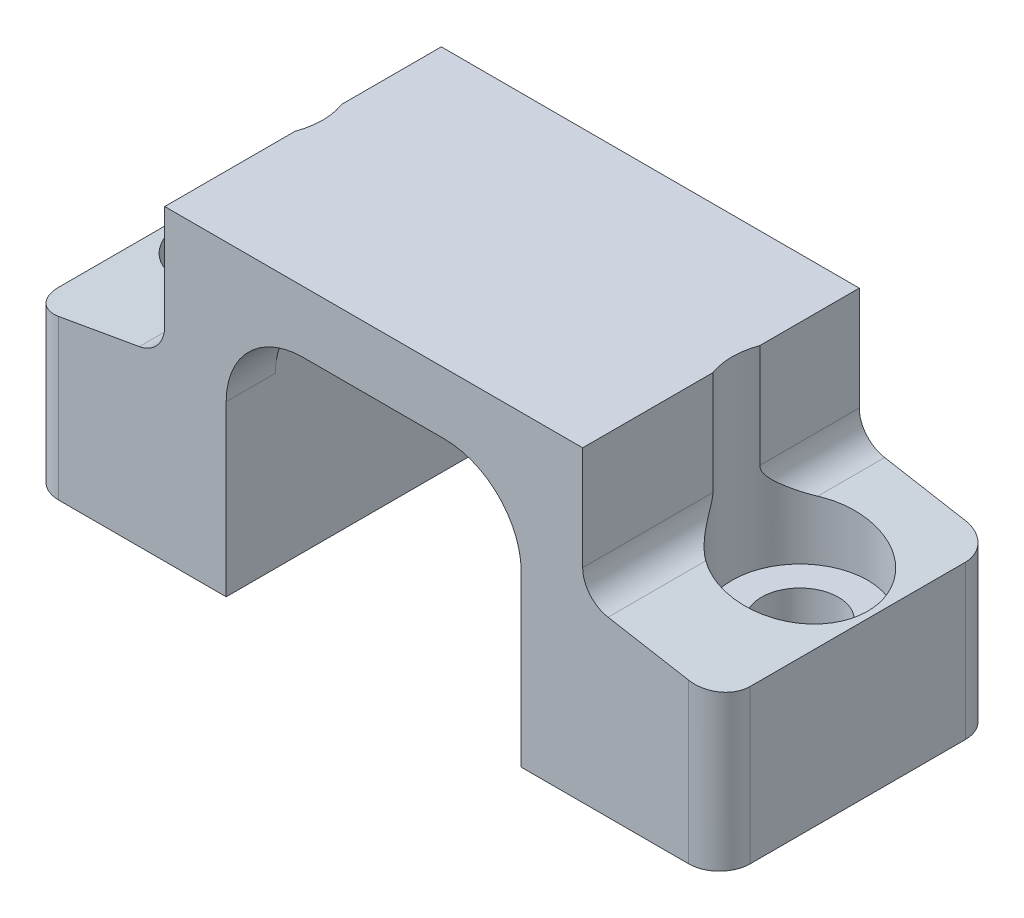
from build123d import *

# Parameters (mm, degrees)
BOSS_EXTRUDE1_DEPTH = 22.86
BOSS_EXTRUDE2_DEPTH = 13.462
BOSS_EXTRUDE3_START = -1.27
BOSS_EXTRUDE3_DEPTH = 1.905
BOSS_EXTRUDE4_START = -1.27
BOSS_EXTRUDE4_DEPTH = 3.81
SKETCH8_R           = 2.8
SKETCH8_R_2         = 1.5875
CUT_EXTRUDE1_DEPTH  = 8
SKETCH9_W           = 28.575
SKETCH9_H           = 11.43
CUT_EXTRUDE2_DEPTH  = 13.7
FILLET1_R           = 1.27


with BuildPart() as part:
    # Sketch1 → Boss-Extrude1 (new body)
    with BuildSketch(Plane.XY):
        Polygon((-6.096, 10.16), (6.096, 10.16), (6.096, 0), (14.2875, 0), (14.2875, 6.35), (8.636, 7.346511931), (8.636, 12.7), (-8.636, 12.7), (-8.636, 7.346511931), (-14.2875, 6.35), (-14.2875, 0), (-6.096, 0), align=None)
    extrude(amount=-BOSS_EXTRUDE1_DEPTH)

    # Sketch2 → Boss-Extrude2 (add)
    with BuildSketch(Plane.XY):
        with BuildLine():
            Line((2.921, 10.16), (6.096, 10.16))
            Line((6.096, 10.16), (6.096, 6.985))
            ThreePointArc((6.096, 6.985), (5.16606403, 9.23006403), (2.921, 10.16))
        make_face()
        with BuildLine():
            Line((-6.096, 10.16), (-6.096, 6.985))
            ThreePointArc((-6.096, 6.985), (-5.16606403, 9.23006403), (-2.921, 10.16))
            Line((-2.921, 10.16), (-6.096, 10.16))
        make_face()
    extrude(amount=-BOSS_EXTRUDE2_DEPTH)

    # Sketch3 → Boss-Extrude3 (add)
    with BuildSketch(Plane.XY.offset(-13.462).offset(BOSS_EXTRUDE3_START)):
        with BuildLine():
            Line((-6.096, 10.16), (-6.096, 6.985))
            ThreePointArc((-6.096, 6.985), (-5.16606403, 9.23006403), (-2.921, 10.16))
            Line((-2.921, 10.16), (-6.096, 10.16))
        make_face()
    extrude(amount=-BOSS_EXTRUDE3_DEPTH)

    # Sketch4 → Boss-Extrude4 (add)
    with BuildSketch(Plane.XY.offset(-16.637).offset(BOSS_EXTRUDE4_START)):
        with BuildLine():
            Line((-6.096, 10.16), (-6.096, 6.985))
            ThreePointArc((-6.096, 6.985), (-5.16606403, 9.23006403), (-2.921, 10.16))
            Line((-2.921, 10.16), (-6.096, 10.16))
        make_face()
    extrude(amount=-BOSS_EXTRUDE4_DEPTH)

    # Sketch6 → Cut-Revolve1 (revolve, cut)
    with BuildSketch(Plane.XY.offset(-5.08)):
        Polygon((11.262482277, -1.27), (12.849982277, -1.27), (12.849982277, 6.60347316), (12.849982277, 9.423392242), (11.262482277, 9.423392242), (11.262482277, 6.883392242), align=None)
    cut_revolve1 = revolve(axis=Axis((11.262482277, -1.27, -5.08), (0, -1, 0)), mode=Mode.SUBTRACT)

    # Mirror1: Cut-Revolve1 across plane
    add(cut_revolve1.mirror(Plane(origin=(0, 0, 0), x_dir=(0, 0, 1), z_dir=(1, 0, 0))), mode=Mode.SUBTRACT)

    # Mirror2: Cut-Revolve1 across plane
    add(cut_revolve1.mirror(Plane.XY.offset(-11.43)), mode=Mode.SUBTRACT)

    # Mirror2 copy 1 sketch → Mirror2 copy 1 (revolve, cut)
    with BuildSketch(Plane(origin=(0, 0, -17.78), x_dir=(-1, 0, 0), z_dir=(0, 0, -1))):
        Polygon((11.262482277, -1.27), (12.849982277, -1.27), (12.849982277, 6.60347316), (12.849982277, 9.423392242), (11.262482277, 9.423392242), (11.262482277, 6.883392242), align=None)
    revolve(axis=Axis((-11.262482277, -1.27, -17.78), (0, -1, 0)), mode=Mode.SUBTRACT)

    # Sketch8 → Cut-Extrude1 (cut)
    with BuildSketch(Plane(origin=(0, 12.7, 0), x_dir=(-1, 0, 0), z_dir=(0, -1, 0))):
        with Locations((11.262482277, 17.78)):
            Circle(SKETCH8_R)
        with Locations((11.262482277, 17.78)):
            Circle(SKETCH8_R_2, mode=Mode.SUBTRACT)
        with Locations((11.262482277, 5.08)):
            Circle(SKETCH8_R)
        with Locations((11.262482277, 5.08)):
            Circle(SKETCH8_R_2, mode=Mode.SUBTRACT)
        with Locations((-11.262482277, 5.08)):
            Circle(SKETCH8_R)
        with Locations((-11.262482277, 5.08)):
            Circle(SKETCH8_R_2, mode=Mode.SUBTRACT)
        with Locations((-11.262482277, 17.78)):
            Circle(SKETCH8_R)
        with Locations((-11.262482277, 17.78)):
            Circle(SKETCH8_R_2, mode=Mode.SUBTRACT)
    extrude(amount=CUT_EXTRUDE1_DEPTH, mode=Mode.SUBTRACT)

    # Sketch9 → Cut-Extrude2 (cut, through all)
    with BuildSketch(Plane(origin=(0, 0, 0), x_dir=(-1, 0, 0), z_dir=(0, -1, 0))):
        with Locations((0, 5.715)):
            Rectangle(SKETCH9_W, SKETCH9_H)
    extrude(amount=-CUT_EXTRUDE2_DEPTH, mode=Mode.SUBTRACT)

    # Fillet1
    fillet1_edges = [part.edges().sort_by_distance(p)[0] for p in [
        (-14.2875, 3.175, -22.86),
        (14.2875, 3.175, -22.86),
        (-8.636, 7.346511931, -14.119821979),
        (-8.636, 7.346511931, -20.805178021),
        (8.636, 7.346511931, -20.805178021),
        (8.636, 7.346511931, -14.119821979),
        (14.2875, 3.175, -11.43),
        (-14.2875, 3.175, -11.43),
    ]]
    fillet(fillet1_edges, radius=FILLET1_R)


solid = part.part
